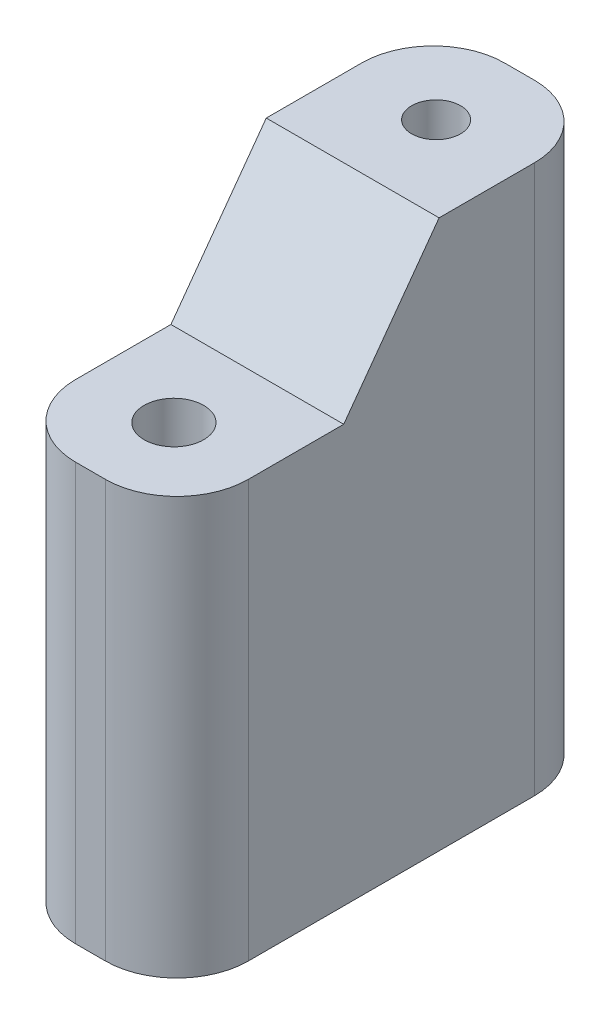
from build123d import *

# Parameters (mm, degrees)
SKETCH1_W                          = 7.25
SKETCH1_H                          = 18
BOSS_EXTRUDE1_DEPTH                = 23
CUT_EXTRUDE1_DEPTH                 = 1
CUT_EXTRUDE1_DEPTH_BACK            = 8.25
M2_5X0_45_TAPPED_HOLE1_D           = 2.05
M2_5X0_45_TAPPED_HOLE1_DEPTH       = 6.35
M2_5X0_45_TAPPED_HOLE1_TIP         = 0.615882135
M2_5X0_45_TAPPED_HOLE2_D           = 2.05
M2_5X0_45_TAPPED_HOLE2_DEPTH       = 6.35
M2_5X0_45_TAPPED_HOLE2_TIP         = 0.615882135
M2_5X0_45_TAPPED_HOLE3_D           = 2.05
M2_5X0_45_TAPPED_HOLE3_DEPTH       = 6.35
M2_5X0_45_TAPPED_HOLE3_CBORE_D     = 2.5
M2_5X0_45_TAPPED_HOLE3_CBORE_DEPTH = 5
M2_5X0_45_TAPPED_HOLE3_TIP         = 0.615882135
FILLET1_R                          = 3


with BuildPart() as part:
    # Sketch1 → Boss-Extrude1 (new body)
    with BuildSketch(Plane(origin=(0, 0, 0), x_dir=(1, 0, 0), z_dir=(0, 1, 0))):
        Rectangle(SKETCH1_W, SKETCH1_H)
    extrude(amount=BOSS_EXTRUDE1_DEPTH)

    # Sketch2 → Cut-Extrude1 (cut, two sides)
    with BuildSketch(Plane.ZY.offset(3.625)) as cut_extrude1_sk:
        Polygon((-77.412327466, 23), (-9, 23), (-2, 23), (2, 17.5), (9, 17.5), (77.412327466, 17.5), (82.269830407, 154.238403027), (-72.554824525, 159.738403027), align=None)
    extrude(amount=CUT_EXTRUDE1_DEPTH, mode=Mode.SUBTRACT)
    extrude(cut_extrude1_sk.sketch, amount=-CUT_EXTRUDE1_DEPTH_BACK, mode=Mode.SUBTRACT)

    # M2.5x0.45 Tapped Hole1
    with Locations(Plane(origin=(0, 0, 0), x_dir=(-1, 0, 0), z_dir=(0, -1, 0))):
        with Locations((0, 0)):
            Hole(M2_5X0_45_TAPPED_HOLE1_D / 2, depth=M2_5X0_45_TAPPED_HOLE1_DEPTH)
            with Locations((0, 0, -(M2_5X0_45_TAPPED_HOLE1_DEPTH + M2_5X0_45_TAPPED_HOLE1_TIP / 2))):  # 118° drill point
                Cone(0, M2_5X0_45_TAPPED_HOLE1_D / 2, M2_5X0_45_TAPPED_HOLE1_TIP, mode=Mode.SUBTRACT)

    # M2.5x0.45 Tapped Hole2
    with Locations(Plane(origin=(0, 23, 0), x_dir=(1, 0, 0), z_dir=(0, 1, 0))):
        with Locations((0, 5.5)):
            Hole(M2_5X0_45_TAPPED_HOLE2_D / 2, depth=M2_5X0_45_TAPPED_HOLE2_DEPTH)
            with Locations((0, 0, -(M2_5X0_45_TAPPED_HOLE2_DEPTH + M2_5X0_45_TAPPED_HOLE2_TIP / 2))):  # 118° drill point
                Cone(0, M2_5X0_45_TAPPED_HOLE2_D / 2, M2_5X0_45_TAPPED_HOLE2_TIP, mode=Mode.SUBTRACT)

    # M2.5x0.45 Tapped Hole3
    with Locations(Plane(origin=(0, 17.5, 0), x_dir=(1, 0, 0), z_dir=(0, 1, 0))):
        with Locations((0, -5.5)):
            CounterBoreHole(M2_5X0_45_TAPPED_HOLE3_D / 2, M2_5X0_45_TAPPED_HOLE3_CBORE_D / 2, M2_5X0_45_TAPPED_HOLE3_CBORE_DEPTH, depth=M2_5X0_45_TAPPED_HOLE3_DEPTH)
            with Locations((0, 0, -(M2_5X0_45_TAPPED_HOLE3_DEPTH + M2_5X0_45_TAPPED_HOLE3_TIP / 2))):  # 118° drill point
                Cone(0, M2_5X0_45_TAPPED_HOLE3_D / 2, M2_5X0_45_TAPPED_HOLE3_TIP, mode=Mode.SUBTRACT)

    # Fillet1
    fillet1_edges = [part.edges().sort_by_distance(p)[0] for p in [
        (3.625, 8.75, 9),
        (-3.625, 8.75, 9),
        (-3.625, 11.5, -9),
        (3.625, 11.5, -9),
    ]]
    fillet(fillet1_edges, radius=FILLET1_R)


solid = part.part
